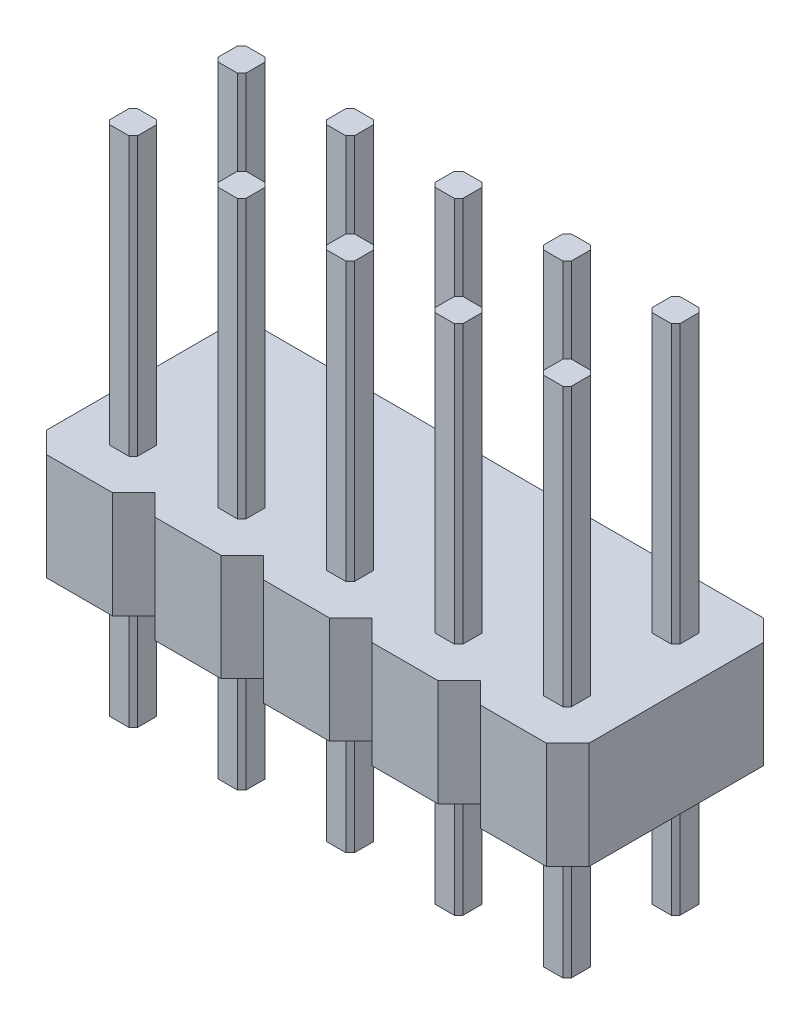
from build123d import *

# Parameters (mm, degrees)
BOSS_EXTRUDE1_DEPTH = 12
LPATTERN1_COUNT     = 2
LPATTERN1_PITCH     = 2.54
BOSS_EXTRUDE2_DEPTH = 2.5
LPATTERN2_COUNT     = 5
LPATTERN2_PITCH     = 2.54


with BuildPart() as part:
    # Sketch1 → Boss-Extrude1 (new body)
    with BuildSketch(Plane(origin=(0, 0, 0), x_dir=(1, 0, 0), z_dir=(0, 1, 0))):
        Polygon((-0.325, 0.225), (-0.225, 0.325), (0.225, 0.325), (0.325, 0.225), (0.325, -0.225), (0.225, -0.325), (-0.225, -0.325), (-0.325, -0.225), align=None)
    extrude(amount=BOSS_EXTRUDE1_DEPTH)


with BuildPart() as lpattern1_1:
    # LPattern1: pattern copy
    add(part.part.moved(Location(Vector(0, 0, -1) * (1 * LPATTERN1_PITCH))))


with BuildPart() as part_1:
    add(part.part)

    add(lpattern1_1.part)  # Boss-Extrude2 merges LPattern1_1
    # Sketch2 → Boss-Extrude2 (add)
    with BuildSketch(Plane(origin=(0, 3, 0), x_dir=(-1, 0, 0), z_dir=(0, -1, 0))):
        Polygon((0.77, 3.824726958), (1.27, 3.324726958), (1.27, -0.755273042), (0.77, -1.255273042), (-0.77, -1.255273042), (-1.27, -0.755273042), (-1.27, 3.324726958), (-0.77, 3.824726958), align=None)
    extrude(amount=-BOSS_EXTRUDE2_DEPTH)


with BuildPart() as lpattern2_1:
    # LPattern2: pattern copy
    add(part_1.part.moved(Location(Vector(-1, 0, 0) * (1 * LPATTERN2_PITCH))))


with BuildPart() as lpattern2_2:
    # LPattern2: pattern copy
    add(part_1.part.moved(Location(Vector(-1, 0, 0) * (2 * LPATTERN2_PITCH))))


with BuildPart() as lpattern2_3:
    # LPattern2: pattern copy
    add(part_1.part.moved(Location(Vector(-1, 0, 0) * (3 * LPATTERN2_PITCH))))


with BuildPart() as lpattern2_4:
    # LPattern2: pattern copy
    add(part_1.part.moved(Location(Vector(-1, 0, 0) * (4 * LPATTERN2_PITCH))))


with BuildPart() as part_2:
    add(part_1.part)

    # Combine1: union LPattern2_1, LPattern2_2, LPattern2_3, LPattern2_4
    add(lpattern2_1.part)
    add(lpattern2_2.part)
    add(lpattern2_3.part)
    add(lpattern2_4.part)


solid = part_2.part
